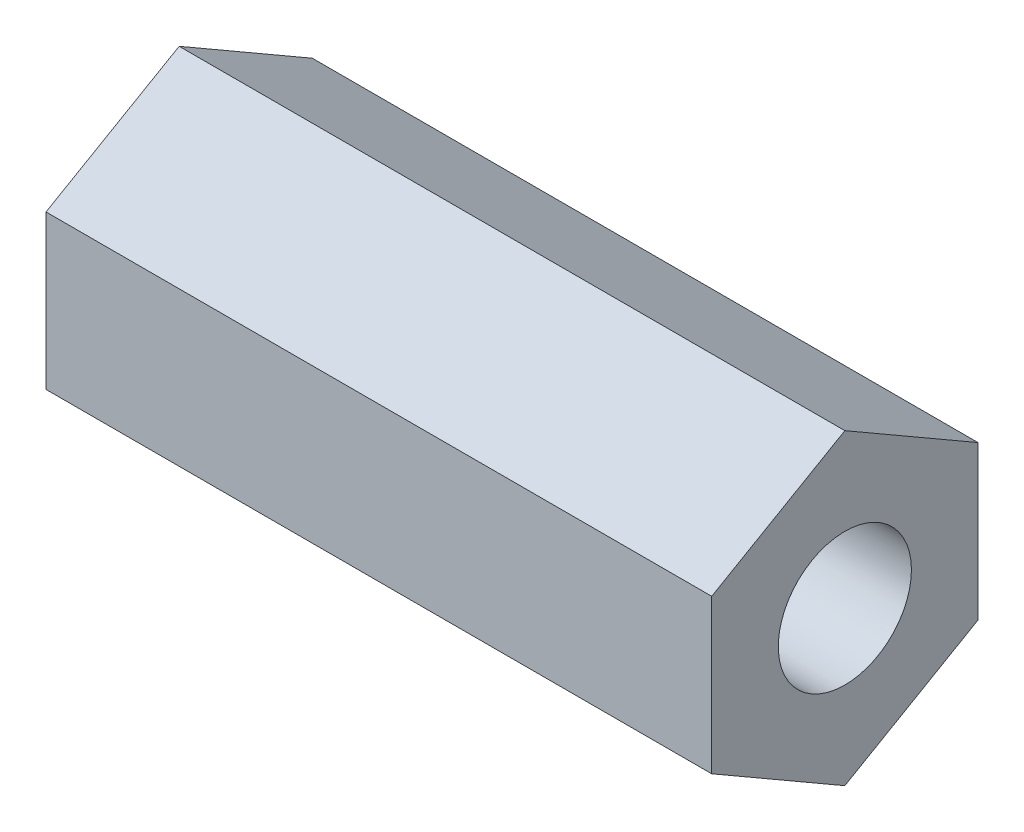
from build123d import *

# Parameters (mm, degrees)
SKETCH_1_R      = 1.5
EXTRUDE_1_DEPTH = 15


with BuildPart() as part:
    # 草图1 → 凸台-拉伸1 (new body)
    with BuildSketch(Plane(origin=(0, 0, 0), x_dir=(0, 0, -1), z_dir=(1, 0, 0))):
        Polygon((-3, 1.732050808), (-3, -1.732050808), (0, -3.464101615), (3, -1.732050808), (3, 1.732050808), (0, 3.464101615), align=None)
        Circle(SKETCH_1_R, mode=Mode.SUBTRACT)
    extrude(amount=EXTRUDE_1_DEPTH)


solid = part.part
